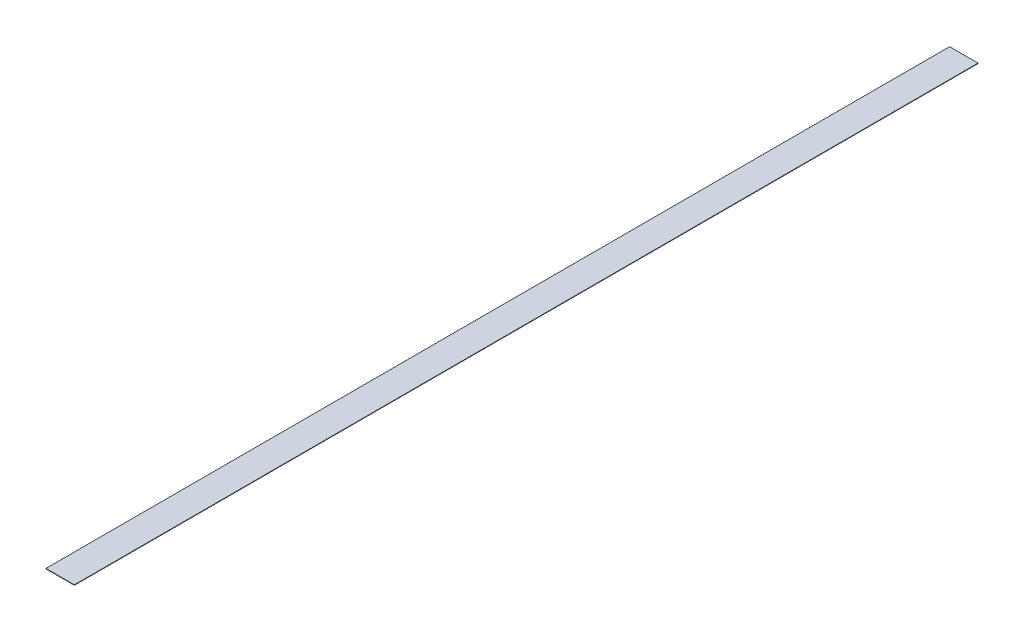
from build123d import *

# Parameters (mm, degrees)
SKETCH1_W           = 50.8
SKETCH1_H           = 1616.075
BOSS_EXTRUDE1_DEPTH = 0.79375


with BuildPart() as part:
    # Sketch1 → Boss-Extrude1 (new body)
    with BuildSketch(Plane(origin=(0, 0, 0), x_dir=(1, 0, 0), z_dir=(0, 1, 0))):
        Rectangle(SKETCH1_W, SKETCH1_H)
    extrude(amount=BOSS_EXTRUDE1_DEPTH)


solid = part.part
